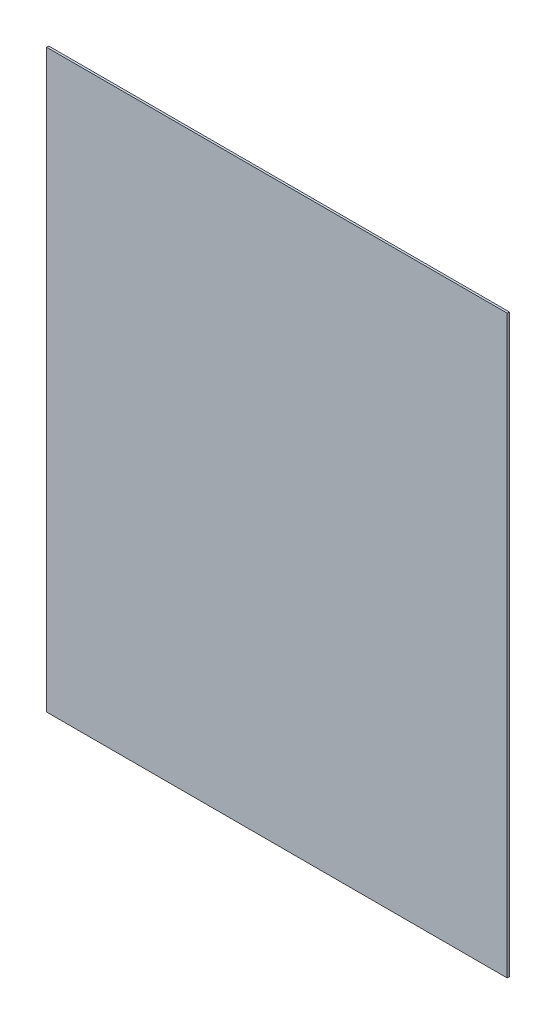
from build123d import *

# Parameters (mm, degrees)
ESQUISSE1_W        = 640
ESQUISSE1_H        = 800
BOSS_EXTRU_1_DEPTH = 3


with BuildPart() as part:
    # Esquisse1 → Boss.-Extru.1 (new body)
    with BuildSketch(Plane.XY):
        with Locations((-320, 400)):
            Rectangle(ESQUISSE1_W, ESQUISSE1_H)
    extrude(amount=BOSS_EXTRU_1_DEPTH)


solid = part.part
